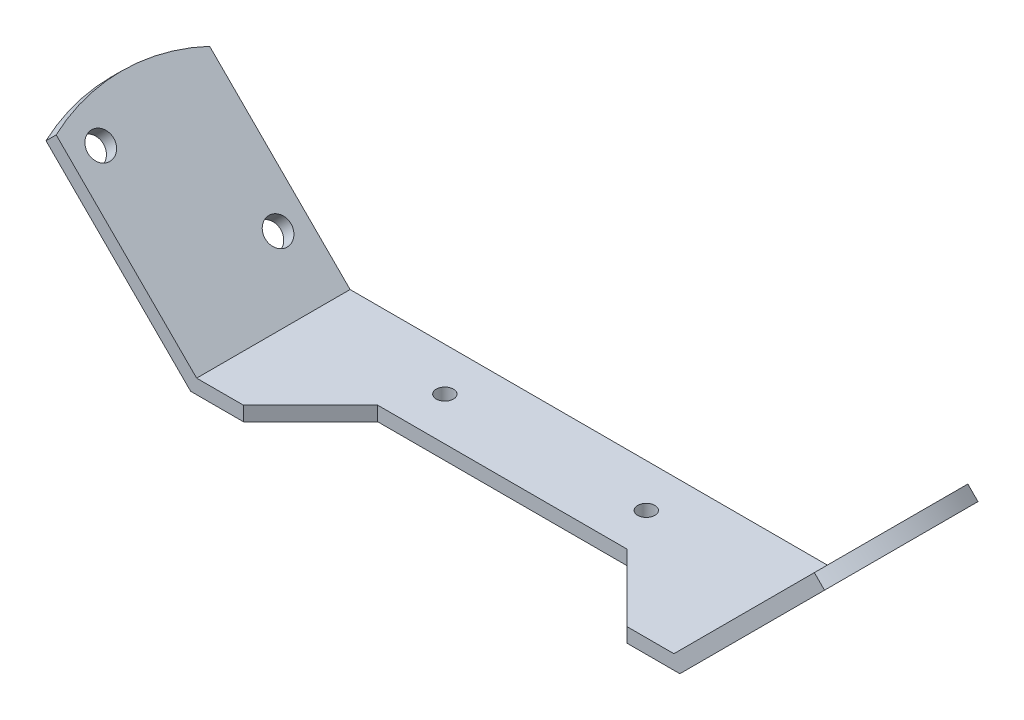
from build123d import *

# Parameters (mm, degrees)
MIDDLE_SKETCH_W               = 5.5
MIDDLE_SKETCH_H               = 16
MIDDLE_SKETCH_W_2             = 26
MIDDLE_SKETCH_H_2             = 9
MIDDLE_EXTRUDE_DEPTH          = 1.5
OFFSHOOT_RIGHT_PLANE_SKETCH_W = 16
OFFSHOOT_RIGHT_PLANE_SKETCH_H = 21.33030278
RIGHT_OFFSHOOT_EXTRUDE_DEPTH  = 1.5
OFFSHOOT_LEFT_PLANE_SKETCH_W  = 16
OFFSHOOT_LEFT_PLANE_SKETCH_H  = 21.33030278
LEFT_OFFSHOOT_EXTRUDE_DEPTH   = 1.5
F_2_7_2_7_DIAMETER_HOLE1_D    = 2.7
F_2_7_2_7_DIAMETER_HOLE2_D    = 2.7
F_1_8_1_8_DIAMETER_HOLE1_D    = 1.8


with BuildPart() as part:
    # Middle Sketch → Middle Extrude (new body)
    with BuildSketch(Plane(origin=(0, 0, 0), x_dir=(1, 0, 0), z_dir=(0, 1, 0))):
        with Locations((-22.75, -3.5)):
            Rectangle(MIDDLE_SKETCH_W, MIDDLE_SKETCH_H)
        Polygon((-20, -11.5), (-20, 4.5), (-13, 4.5), (-13, -4.5), align=None)
        Rectangle(MIDDLE_SKETCH_W_2, MIDDLE_SKETCH_H_2)
        Polygon((13, 4.5), (20, 4.5), (20, -11.5), (13, -4.5), align=None)
        with Locations((22.75, -3.5)):
            Rectangle(MIDDLE_SKETCH_W, MIDDLE_SKETCH_H)
    extrude(amount=MIDDLE_EXTRUDE_DEPTH)

    # Offshoot Right Plane Sketch → Right Offshoot Extrude (add)
    with BuildSketch(Plane(origin=(12.75, -12.75, 0), x_dir=(0, 0, -1), z_dir=(0.707106781, -0.707106781, 0))):
        with BuildLine():
            Line((4.5, 39.3615257), (-11.5, 39.3615257))
            ThreePointArc((-11.5, 39.3615257), (-3.5, 41.03122292), (4.5, 39.3615257))
        make_face()
        with Locations((-3.5, 28.69637431)):
            Rectangle(OFFSHOOT_RIGHT_PLANE_SKETCH_W, OFFSHOOT_RIGHT_PLANE_SKETCH_H)
    extrude(amount=-RIGHT_OFFSHOOT_EXTRUDE_DEPTH)

    # Offshoot Left Plane Sketch → Left Offshoot Extrude (add)
    with BuildSketch(Plane(origin=(-12.75, -12.75, 0), x_dir=(0, 0, -1), z_dir=(-0.707106781, -0.707106781, 0))):
        with Locations((-3.5, -28.69637431)):
            Rectangle(OFFSHOOT_LEFT_PLANE_SKETCH_W, OFFSHOOT_LEFT_PLANE_SKETCH_H)
        with BuildLine():
            ThreePointArc((4.5, -39.3615257), (-3.5, -41.03122292), (-11.5, -39.3615257))
            Line((-11.5, -39.3615257), (4.5, -39.3615257))
        make_face()
    extrude(amount=-LEFT_OFFSHOOT_EXTRUDE_DEPTH)

    # Ø2.7 (2.7) Diameter Hole1 (through all)
    with Locations(Plane(origin=(-11.689339828, -11.689339828, 0), x_dir=(0.707106781, -0.707106781, 0), z_dir=(0.707106781, 0.707106781, 0))):
        with Locations((-37.03122292, -8.5), (-25.03122292, 1.5)):
            Hole(F_2_7_2_7_DIAMETER_HOLE1_D / 2)

    # Ø2.7 (2.7) Diameter Hole2 (through all)
    with Locations(Plane(origin=(11.689339828, -11.689339828, 0), x_dir=(0.707106781, 0.707106781, 0), z_dir=(-0.707106781, 0.707106781, 0))):
        with Locations((25.03122292, 1.5), (37.03122292, -8.5)):
            Hole(F_2_7_2_7_DIAMETER_HOLE2_D / 2)

    # Ø1.8 (1.8) Diameter Hole1 (through all)
    with Locations(Plane(origin=(0, 1.5, 0), x_dir=(1, 0, 0), z_dir=(0, 1, 0))):
        with Locations((-10.5, 0), (10.5, 0)):
            Hole(F_1_8_1_8_DIAMETER_HOLE1_D / 2)


solid = part.part
